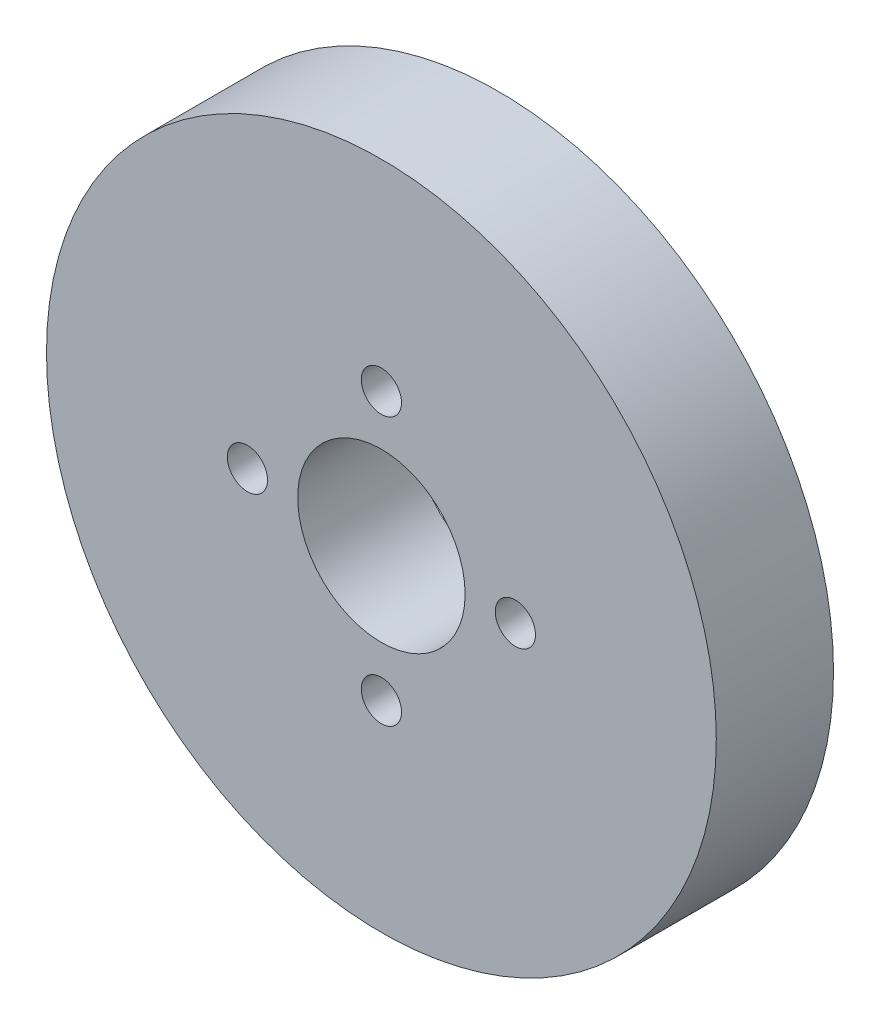
from build123d import *

# Parameters (mm, degrees)
ESQUISSE1_R        = 20
ESQUISSE1_R_2      = 5
BOSS_EXTRU_1_DEPTH = 7
D_GAGEMENT_M21_D   = 2.4


with BuildPart() as part:
    # Esquisse1 → Boss.-Extru.1 (new body)
    with BuildSketch(Plane.XY):
        Circle(ESQUISSE1_R)
        Circle(ESQUISSE1_R_2, mode=Mode.SUBTRACT)
    extrude(amount=BOSS_EXTRU_1_DEPTH)

    # Dégagement M21 (through all)
    with Locations(Plane.XY.offset(7)):
        with Locations((0, 8), (8, 0), (0, -8), (-8, 0), (0, 0)):
            Hole(D_GAGEMENT_M21_D / 2)


solid = part.part
